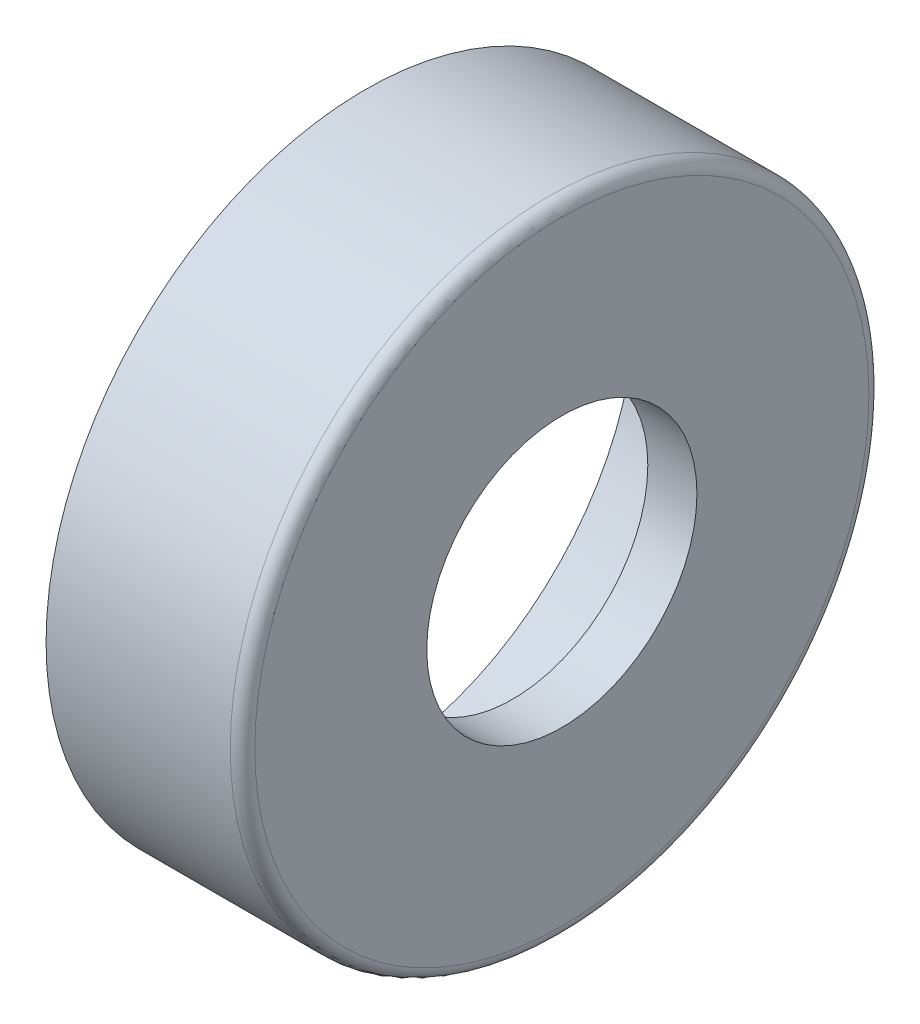
from build123d import *

# Parameters (mm, degrees)
CONG_1_R = 0.5


with BuildPart() as part:
    # Esquisse1 → Révolution1 (revolve)
    with BuildSketch(Plane.XY, mode=Mode.PRIVATE) as r_volution1_sk:
        with BuildLine():
            Line((-3.5, 13), (4.5, 13))
            Line((4.5, 13), (4.5, 5.5))
            Line((4.5, 5.5), (2.5, 5.5))
            Line((2.5, 5.5), (2.5, 8.5))
            ThreePointArc((2.5, 8.5), (1.767766953, 10.267766953), (0, 11))
            Line((0, 11), (-3.5, 11))
            Line((-3.5, 11), (-3.5, 13))
        make_face()
    revolve(r_volution1_sk.sketch.rotate(Axis((-12.986342457, 0, 0), (1, 0, 0)), 90), axis=Axis((-12.986342457, 0, 0), (1, 0, 0)))  # turned: the seam where the file's is

    # Congé1
    cong_1_edges = [part.edges().sort_by_distance(p)[0] for p in [
        (4.5, 0, -13),
    ]]
    fillet(cong_1_edges, radius=CONG_1_R)


solid = part.part
